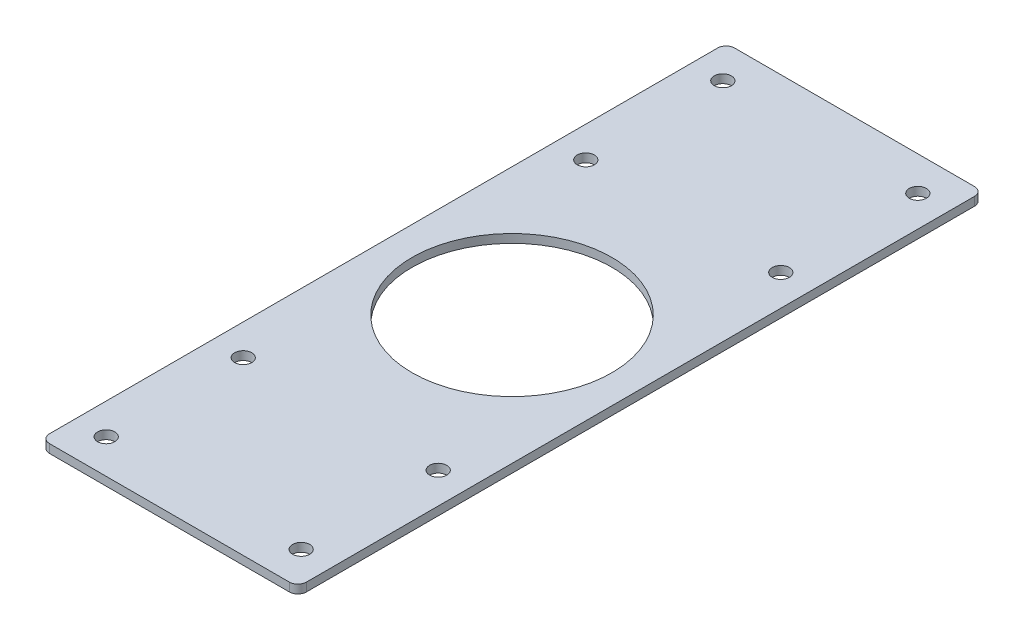
from build123d import *

# Parameters (mm, degrees)
SKETCH1_W           = 90
SKETCH1_H           = 240
SKETCH1_R           = 35
SKETCH1_R_2         = 3
BOSS_EXTRUDE1_DEPTH = 3
FILLET1_R           = 3


with BuildPart() as part:
    # Sketch1 → Boss-Extrude1 (new body)
    with BuildSketch(Plane(origin=(0, 0, 0), x_dir=(1, 0, 0), z_dir=(0, 1, 0))):
        Rectangle(SKETCH1_W, SKETCH1_H)
        Circle(SKETCH1_R, mode=Mode.SUBTRACT)
        with Locations((-34.15, 60)):
            Circle(SKETCH1_R_2, mode=Mode.SUBTRACT)
        with Locations((34.15, 60)):
            Circle(SKETCH1_R_2, mode=Mode.SUBTRACT)
        with Locations((34.15, -60)):
            Circle(SKETCH1_R_2, mode=Mode.SUBTRACT)
        with Locations((-34.15, -60)):
            Circle(SKETCH1_R_2, mode=Mode.SUBTRACT)
        with Locations((-34.15, 108)):
            Circle(SKETCH1_R_2, mode=Mode.SUBTRACT)
        with Locations((34.15, 108)):
            Circle(SKETCH1_R_2, mode=Mode.SUBTRACT)
        with Locations((-34.15, -108)):
            Circle(SKETCH1_R_2, mode=Mode.SUBTRACT)
        with Locations((34.15, -108)):
            Circle(SKETCH1_R_2, mode=Mode.SUBTRACT)
    extrude(amount=BOSS_EXTRUDE1_DEPTH)

    # Fillet1
    fillet1_edges = [part.edges().sort_by_distance(p)[0] for p in [
        (45, 1.5, 120),
        (-45, 1.5, 120),
        (-45, 1.5, -120),
        (45, 1.5, -120),
    ]]
    fillet(fillet1_edges, radius=FILLET1_R)


solid = part.part
